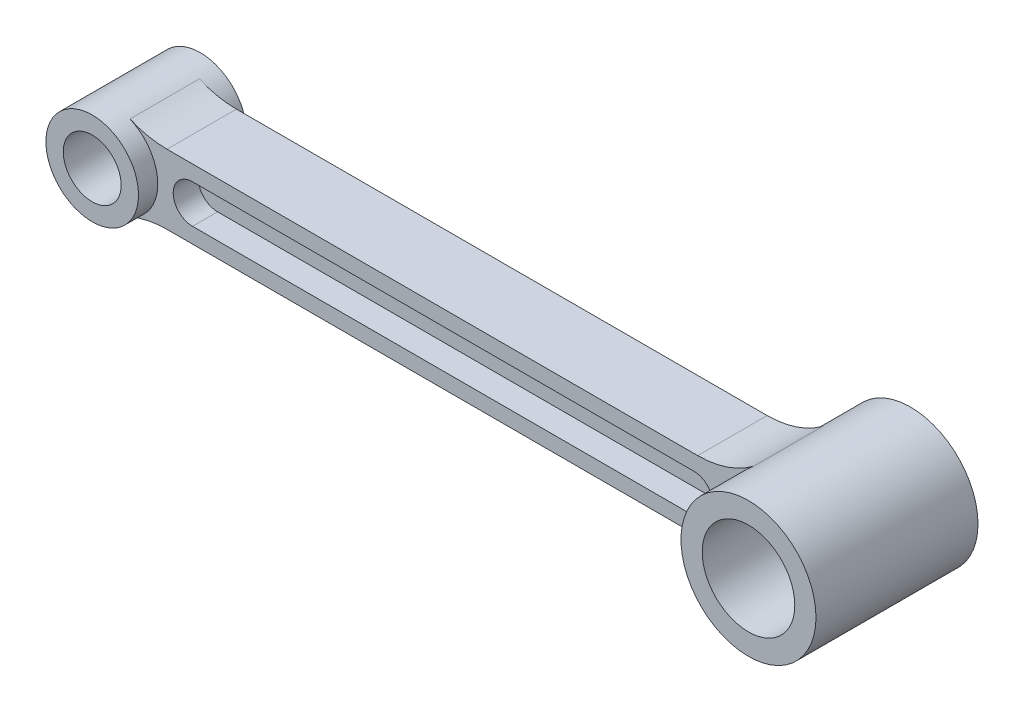
from build123d import *

# Parameters (mm, degrees)
SKETCH1_R           = 12
SKETCH1_R_2         = 7.5
BOSS_EXTRUDE1_DEPTH = 14
SKETCH1_5_R         = 17.5
SKETCH1_5_R_2       = 12
BOSS_EXTRUDE3_DEPTH = 21
BOSS_EXTRUDE4_DEPTH = 9
CUT_EXTRUDE3_START  = 2.5
CUT_EXTRUDE3_DEPTH  = 6.5
FILLET1_R           = 24


with BuildPart() as part:
    # Sketch1 → Boss-Extrude1 (new body, symmetric)
    with BuildSketch(Plane.XY):
        Circle(SKETCH1_R)
        Circle(SKETCH1_R_2, mode=Mode.SUBTRACT)
    extrude(amount=BOSS_EXTRUDE1_DEPTH, both=True)



with BuildPart() as body_2:
    # Sketch1_5 → Boss-Extrude3 (new body, symmetric)
    with BuildSketch(Plane.XY):
        with Locations((177.137212096, 0)):
            Circle(SKETCH1_5_R)
        with Locations((177.137212096, 0)):
            Circle(SKETCH1_5_R_2, mode=Mode.SUBTRACT)
    extrude(amount=BOSS_EXTRUDE3_DEPTH, both=True)


with BuildPart() as part_1:
    add(part.part)

    add(body_2.part)  # Boss-Extrude4 merges body 2
    # Sketch1_6 → Boss-Extrude4 (add, symmetric)
    with BuildSketch(Plane.XY):
        with BuildLine():
            Line((162.128881076, 9), (7.937253933, 9))
            ThreePointArc((7.937253933, 9), (10.937253933, 4.937253933), (12, 0))
            ThreePointArc((12, 0), (10.937253933, -4.937253933), (7.937253933, -9))
            Line((7.937253933, -9), (162.128881076, -9))
            ThreePointArc((162.128881076, -9), (159.637212096, 0), (162.128881076, 9))
        make_face()
    extrude(amount=BOSS_EXTRUDE4_DEPTH, both=True)

    # Sketch2 → Cut-Extrude3 (cut)
    with BuildSketch(Plane.XY.offset(CUT_EXTRUDE3_START)):
        with BuildLine():
            Line((21, 5), (151, 5))
            ThreePointArc((151, 5), (156, 0), (151, -5))
            Line((151, -5), (21, -5))
            ThreePointArc((21, -5), (16, 0), (21, 5))
        make_face()
    cut_extrude3 = extrude(amount=CUT_EXTRUDE3_DEPTH, mode=Mode.SUBTRACT)

    # Mirror1: Cut-Extrude3 across plane
    add(cut_extrude3.mirror(Plane.XY), mode=Mode.SUBTRACT)

    # Fillet1
    fillet1_edges = [part_1.edges().sort_by_distance(p)[0] for p in [
        (7.937253933, 9, 0),
        (7.937253933, -9, 0),
        (162.128881076, -9, 0),
        (162.128881076, 9, 0),
    ]]
    fillet(fillet1_edges, radius=FILLET1_R)


solid = part_1.part
